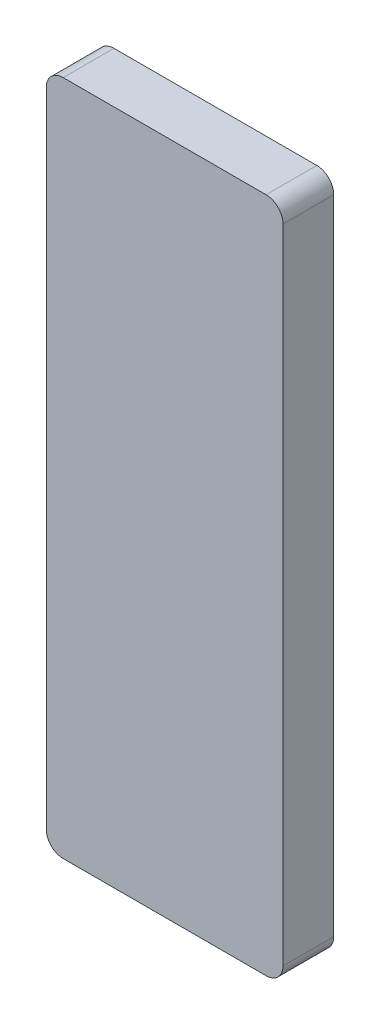
from build123d import *

# Parameters (mm, degrees)
ESQUISSE1_W        = 42
ESQUISSE1_H        = 120
BOSS_EXTRU_1_DEPTH = 9
CONG_1_R           = 3


with BuildPart() as part:
    # Esquisse1 → Boss.-Extru.1 (new body)
    with BuildSketch(Plane.XY):
        Rectangle(ESQUISSE1_W, ESQUISSE1_H)
    extrude(amount=BOSS_EXTRU_1_DEPTH)

    # Congé1
    cong_1_edges = [part.edges().sort_by_distance(p)[0] for p in [
        (-21, 60, 4.5),
        (21, 60, 4.5),
        (21, -60, 4.5),
        (-21, -60, 4.5),
    ]]
    fillet(cong_1_edges, radius=CONG_1_R)


solid = part.part
